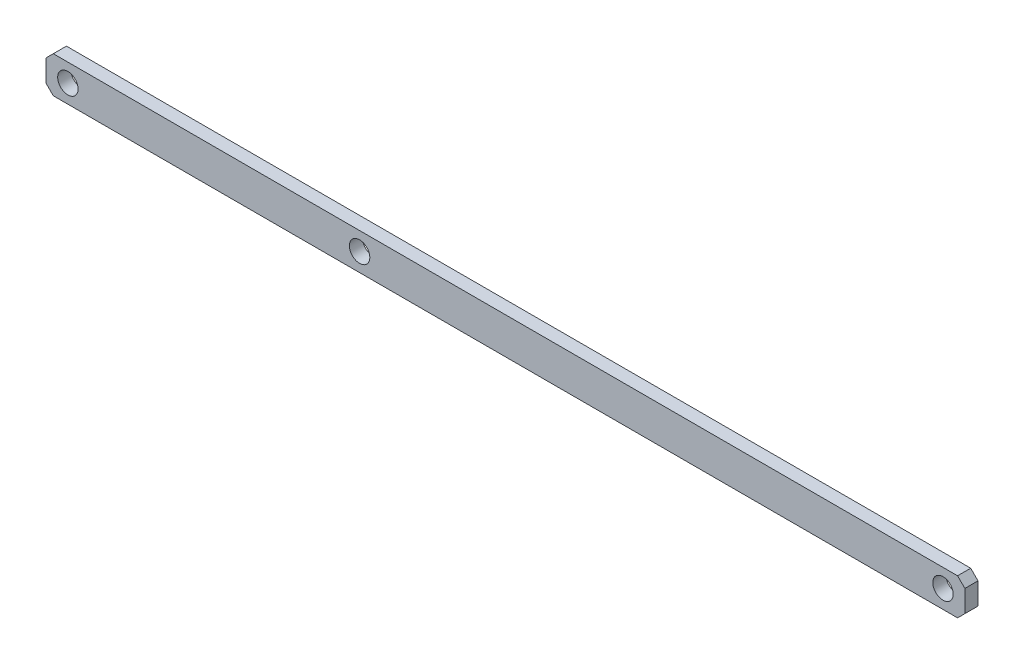
from build123d import *

# Parameters (mm, degrees)
SKETCH_1_R      = 7
EXTRUDE_1_DEPTH = 4.5


with BuildPart() as part:
    # 草圖1 → 填料-伸長1 (new body, symmetric)
    with BuildSketch(Plane.XY):
        Polygon((-215, 7.5), (-210, 12.5), (410, 12.5), (415, 7.5), (415, -7.5), (410, -12.5), (-210, -12.5), (-215, -7.5), align=None)
        Circle(SKETCH_1_R, mode=Mode.SUBTRACT)
        with Locations((400, 0)):
            Circle(SKETCH_1_R, mode=Mode.SUBTRACT)
        with Locations((-200, 0)):
            Circle(SKETCH_1_R, mode=Mode.SUBTRACT)
    extrude(amount=EXTRUDE_1_DEPTH, both=True)


solid = part.part
